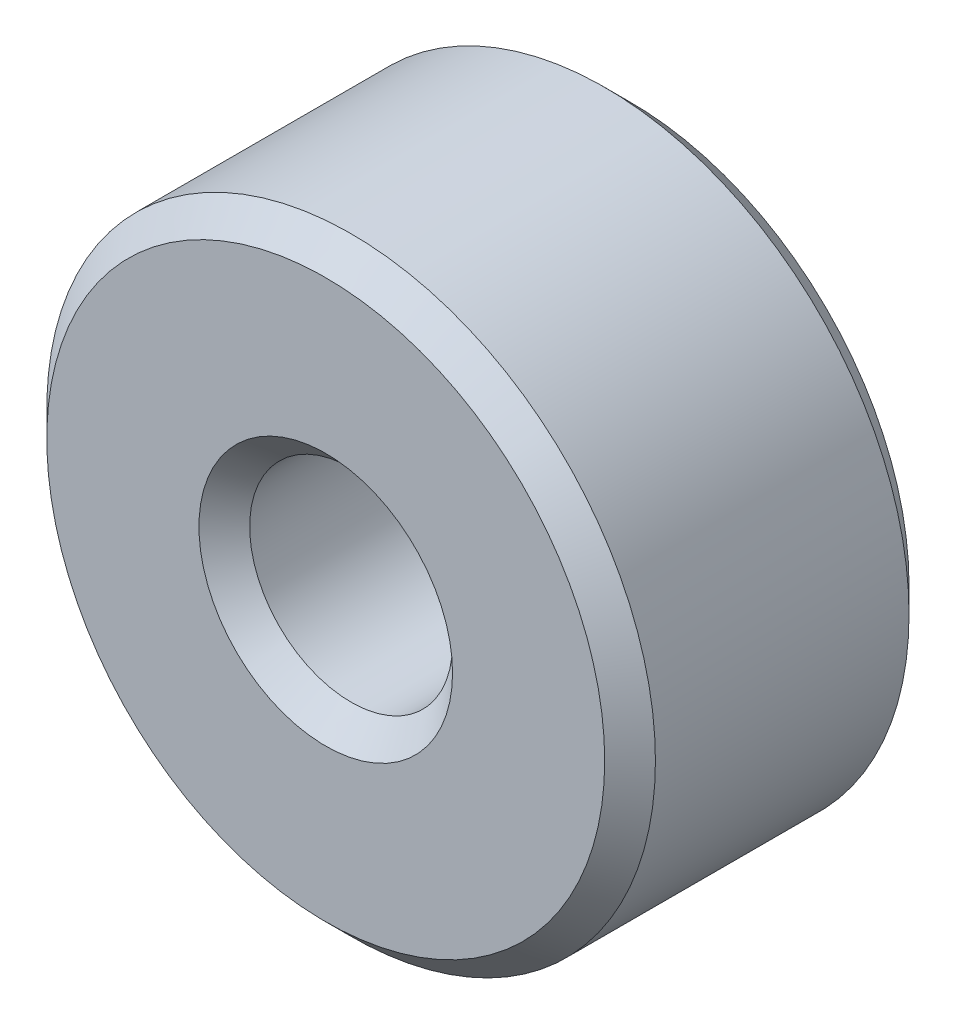
from build123d import *

# Parameters (mm, degrees)
SKETCH1_R           = 3
SKETCH1_R_2         = 1
EXTRUDE_THIN1_DEPTH = 3
CHAMFER1_SIZE       = 0.25


with BuildPart() as part:
    # Sketch1 → Extrude-Thin1 (new body)
    with BuildSketch(Plane.XY):
        Circle(SKETCH1_R)
        Circle(SKETCH1_R_2, mode=Mode.SUBTRACT)
    extrude(amount=EXTRUDE_THIN1_DEPTH)

    # Chamfer1
    chamfer1_edges = [part.edges().sort_by_distance(p)[0] for p in [
        (-3, 0, 0),
        (-3, 0, 3),
        (-1, 0, 0),
        (-1, 0, 3),
    ]]
    chamfer(chamfer1_edges, length=CHAMFER1_SIZE)


solid = part.part
